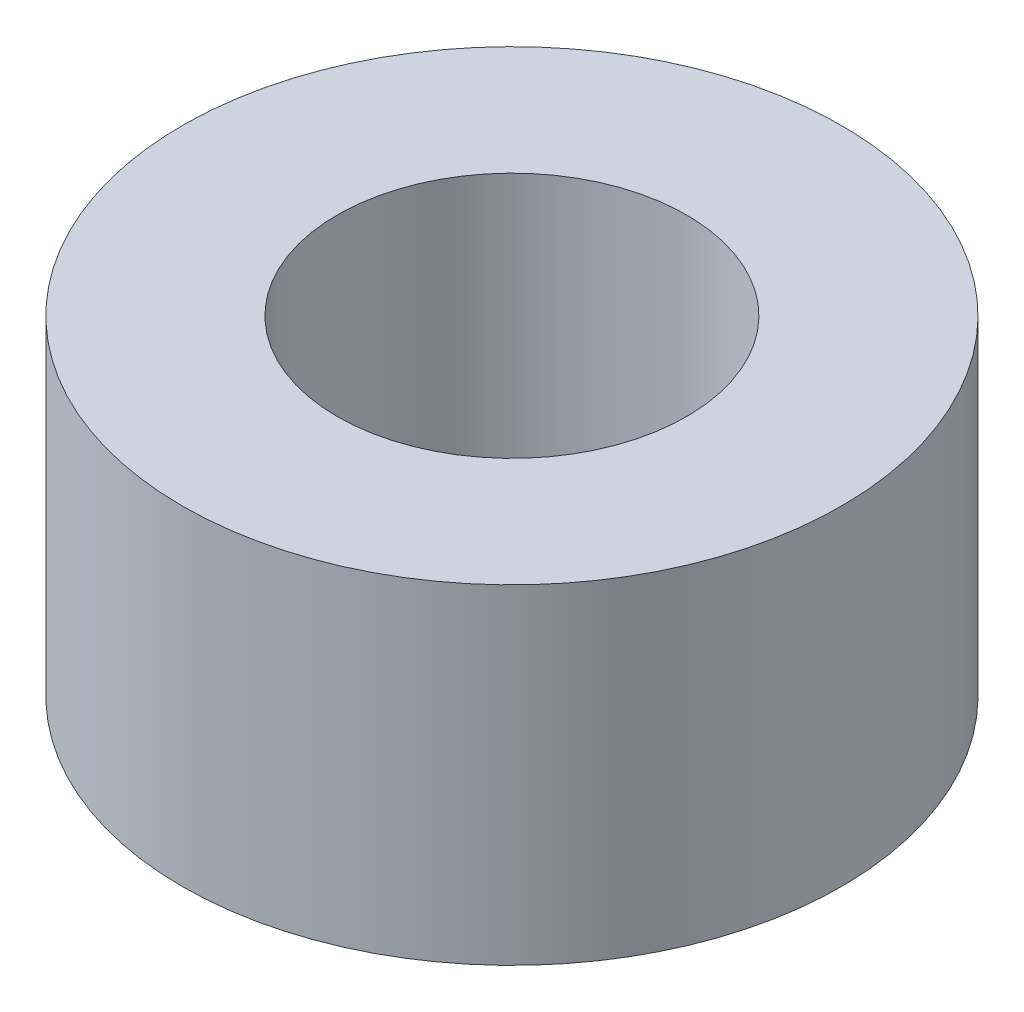
from build123d import *

# Parameters (mm, degrees)
SKETCH1_R           = 5
SKETCH1_R_2         = 2.65
BOSS_EXTRUDE1_DEPTH = 5


with BuildPart() as part:
    # Sketch1 → Boss-Extrude1 (new body)
    with BuildSketch(Plane(origin=(0, 0, 0), x_dir=(1, 0, 0), z_dir=(0, 1, 0))):
        Circle(SKETCH1_R)
        Circle(SKETCH1_R_2, mode=Mode.SUBTRACT)
    extrude(amount=BOSS_EXTRUDE1_DEPTH)


solid = part.part
